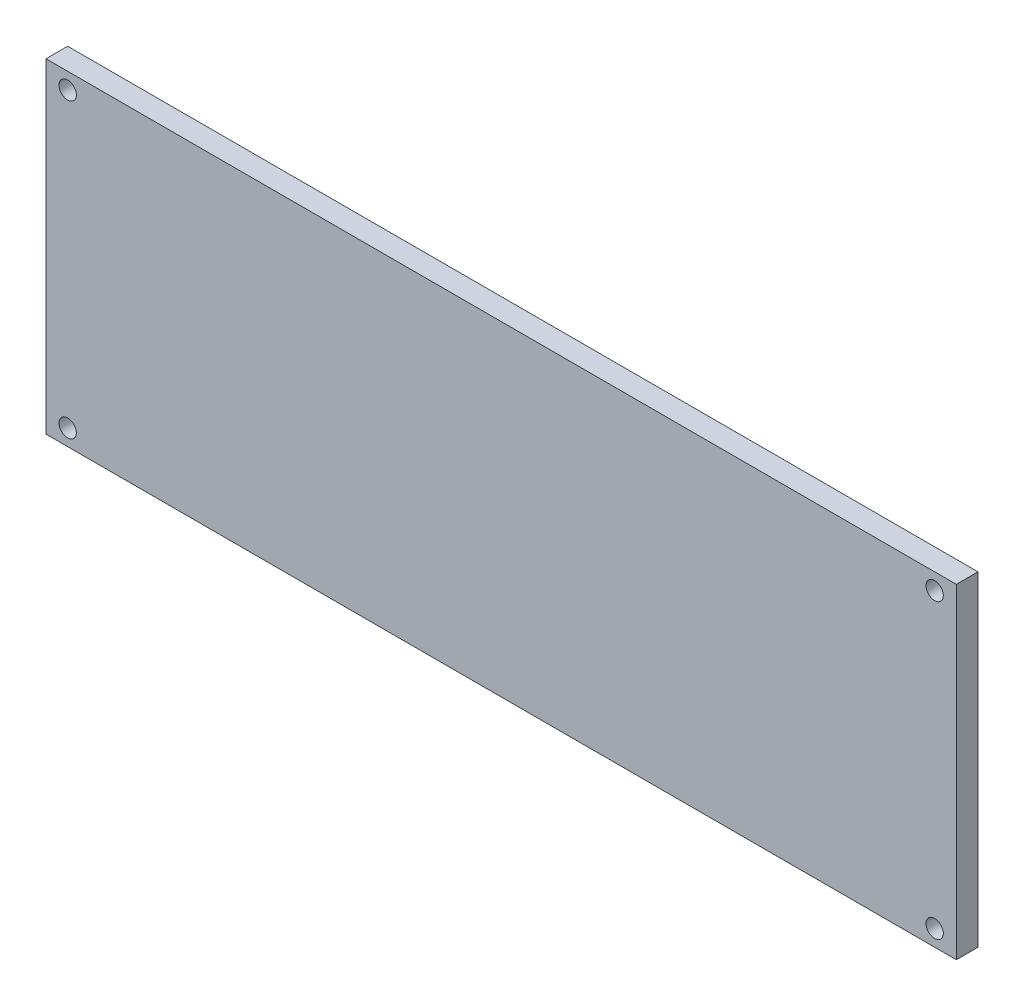
from build123d import *

# Parameters (mm, degrees)
SKETCH1_W           = 210
SKETCH1_H           = 75
BOSS_EXTRUDE1_DEPTH = 5
SKETCH2_R           = 2
CUT_EXTRUDE2_DEPTH  = 5


with BuildPart() as part:
    # Sketch1 → Boss-Extrude1 (new body)
    with BuildSketch(Plane.XY):
        with Locations((105, 37.5)):
            Rectangle(SKETCH1_W, SKETCH1_H)
    extrude(amount=BOSS_EXTRUDE1_DEPTH)

    # Sketch2 → Cut-Extrude2 (cut)
    with BuildSketch(Plane(origin=(0, 0, 0), x_dir=(-1, 0, 0), z_dir=(0, 0, -1))):
        with Locations((-205, 71.25)):
            Circle(SKETCH2_R)
        with Locations((-5, 71.25)):
            Circle(SKETCH2_R)
        with Locations((-5, 3.75)):
            Circle(SKETCH2_R)
        with Locations((-205, 3.75)):
            Circle(SKETCH2_R)
    extrude(amount=-CUT_EXTRUDE2_DEPTH, mode=Mode.SUBTRACT)


solid = part.part
